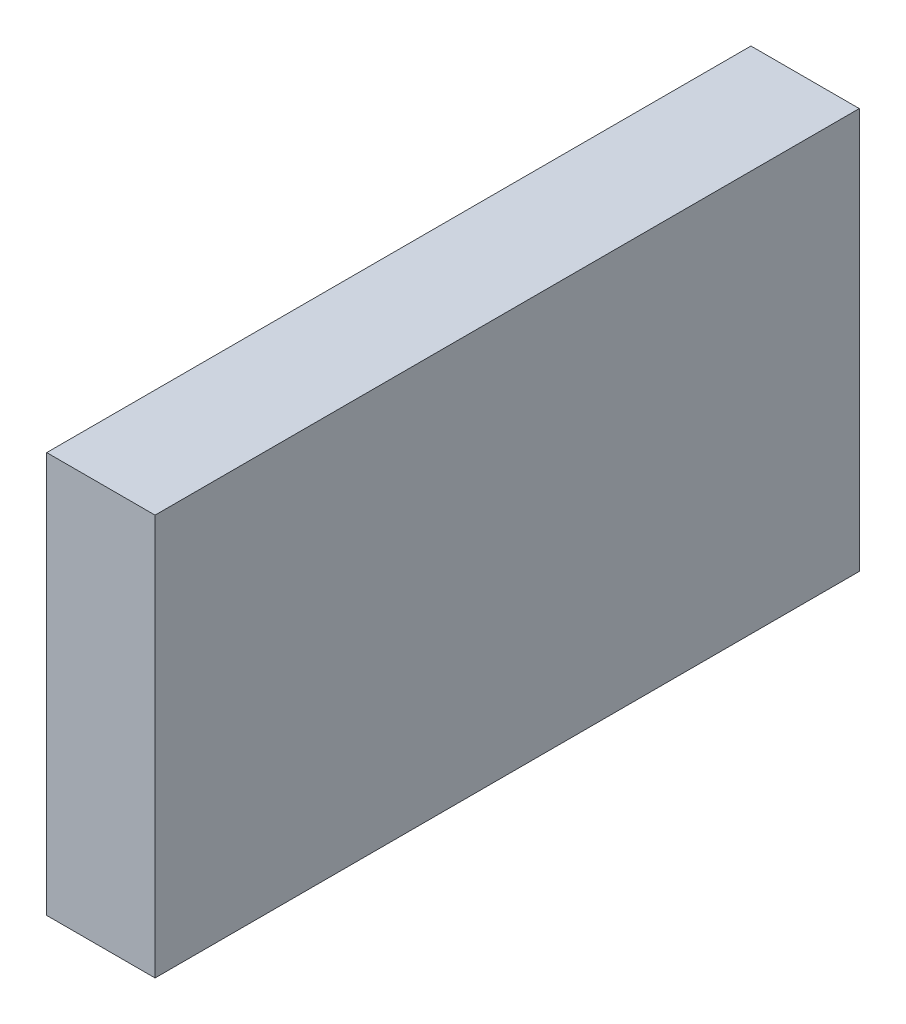
from build123d import *

# Parameters (mm, degrees)
SKETCH1_W           = 5.08
SKETCH1_H           = 18.796
BOSS_EXTRUDE1_DEPTH = 33.02


with BuildPart() as part:
    # Sketch1 → Boss-Extrude1 (new body)
    with BuildSketch(Plane.XY):
        with Locations((2.54, 9.398)):
            Rectangle(SKETCH1_W, SKETCH1_H)
    extrude(amount=BOSS_EXTRUDE1_DEPTH)


solid = part.part
